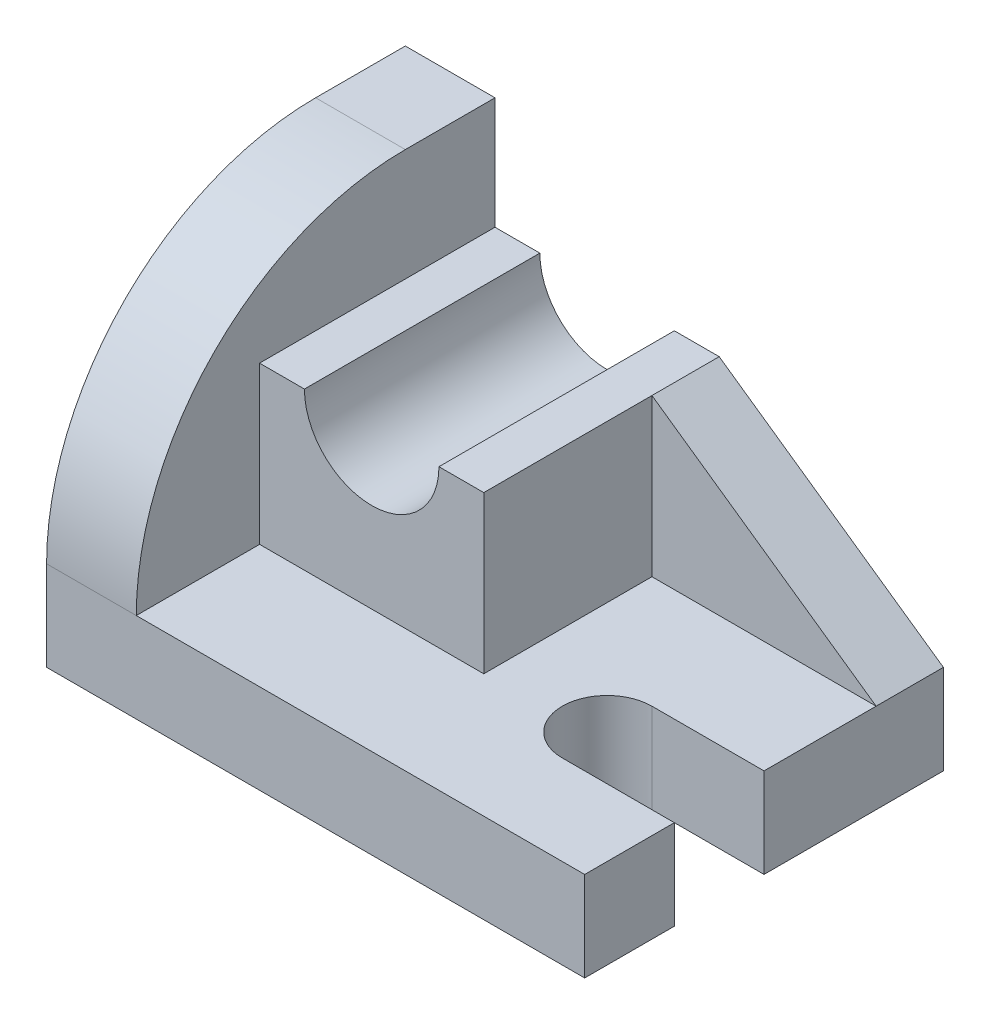
from build123d import *

# Parameters (mm, degrees)
SKETCH1_W           = 64
SKETCH1_H           = 16
BOSS_EXTRUDE1_DEPTH = 96
CUT_EXTRUDE1_DEPTH  = 17
BOSS_EXTRUDE2_DEPTH = 12
SKETCH5_W           = 40
SKETCH5_H           = 42
BOSS_EXTRUDE3_DEPTH = 28
SKETCH11_W          = 16
SKETCH11_H          = 64
BOSS_EXTRUDE6_DEPTH = 48
FILLET2_R           = 48
CUT_EXTRUDE4_DEPTH  = 43


with BuildPart() as part:
    # Sketch1 → Boss-Extrude1 (new body)
    with BuildSketch(Plane(origin=(0, 0, 0), x_dir=(0, 0, -1), z_dir=(1, 0, 0))):
        Rectangle(SKETCH1_W, SKETCH1_H)
    extrude(amount=-BOSS_EXTRUDE1_DEPTH)

    # Sketch3 → Cut-Extrude1 (cut, through all)
    with BuildSketch(Plane(origin=(0, 8, 0), x_dir=(1, 0, 0), z_dir=(0, 1, 0))):
        with BuildLine():
            Line((-20, 0), (0, 0))
            Line((0, 0), (0, -16))
            Line((0, -16), (-20, -16))
            ThreePointArc((-20, -16), (-28, -8), (-20, 0))
        make_face()
    extrude(amount=-CUT_EXTRUDE1_DEPTH, mode=Mode.SUBTRACT)

    # Sketch4 → Boss-Extrude2 (add)
    with BuildSketch(Plane(origin=(0, 0, -32), x_dir=(-1, 0, 0), z_dir=(0, 0, -1))):
        Polygon((0, 8), (40, 8), (40, 36), align=None)
    extrude(amount=-BOSS_EXTRUDE2_DEPTH)

    # Sketch5 → Boss-Extrude3 (add)
    with BuildSketch(Plane(origin=(0, 8, 0), x_dir=(1, 0, 0), z_dir=(0, 1, 0))):
        with Locations((-60, 11)):
            Rectangle(SKETCH5_W, SKETCH5_H)
    extrude(amount=BOSS_EXTRUDE3_DEPTH)

    # Sketch11 → Boss-Extrude6 (add)
    with BuildSketch(Plane(origin=(0, 8, 0), x_dir=(1, 0, 0), z_dir=(0, 1, 0))):
        with Locations((-88, 0)):
            Rectangle(SKETCH11_W, SKETCH11_H)
    extrude(amount=BOSS_EXTRUDE6_DEPTH)

    # Fillet2
    fillet2_edges = [part.edges().sort_by_distance(p)[0] for p in [
        (-88, 56, 32),
    ]]
    fillet(fillet2_edges, radius=FILLET2_R)

    # Sketch13 → Cut-Extrude4 (cut, through all)
    with BuildSketch(Plane.XY.offset(10)):
        with BuildLine():
            Line((-48, 36), (-72, 36))
            ThreePointArc((-72, 36), (-60, 24), (-48, 36))
        make_face()
    extrude(amount=-CUT_EXTRUDE4_DEPTH, mode=Mode.SUBTRACT)


solid = part.part
